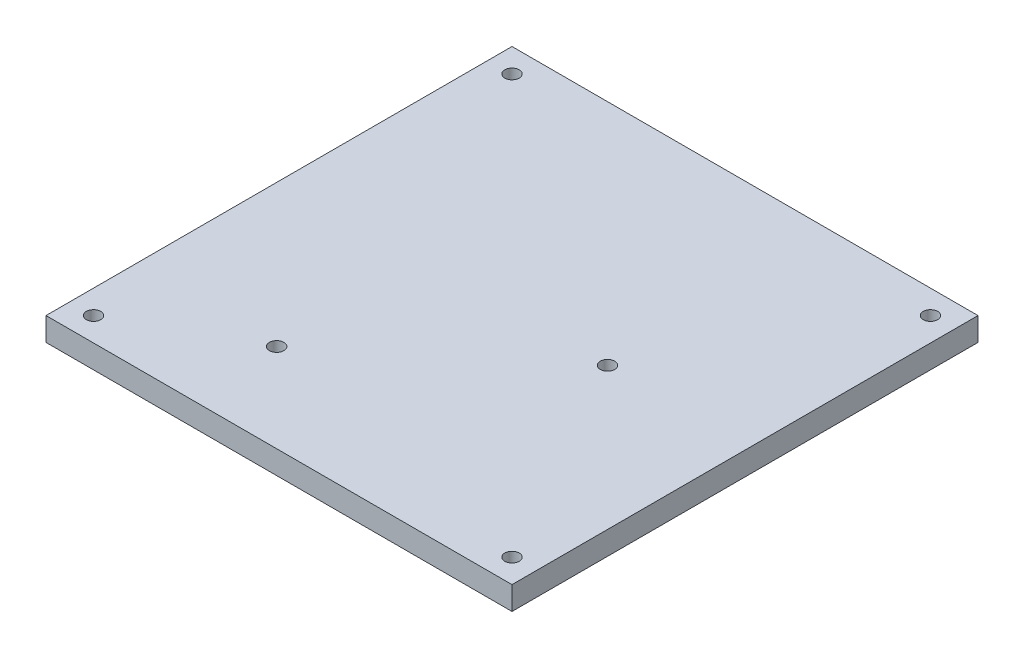
from build123d import *

# Parameters (mm, degrees)
SKETCH1_W           = 100
SKETCH1_H           = 100
SKETCH1_R           = 1.55
BOSS_EXTRUDE1_DEPTH = 5


with BuildPart() as part:
    # Sketch1 → Boss-Extrude1 (new body)
    with BuildSketch(Plane(origin=(0, 0, 0), x_dir=(1, 0, 0), z_dir=(0, 1, 0))):
        Rectangle(SKETCH1_W, SKETCH1_H)
        with Locations((-44.9, 44.9)):
            Circle(SKETCH1_R, mode=Mode.SUBTRACT)
        with Locations((44.9, 44.9)):
            Circle(SKETCH1_R, mode=Mode.SUBTRACT)
        with Locations((44.9, -44.9)):
            Circle(SKETCH1_R, mode=Mode.SUBTRACT)
        with Locations((-44.9, -44.9)):
            Circle(SKETCH1_R, mode=Mode.SUBTRACT)
        with Locations((-19.5, -31)):
            Circle(SKETCH1_R, mode=Mode.SUBTRACT)
        with Locations((19.5, 1)):
            Circle(SKETCH1_R, mode=Mode.SUBTRACT)
    extrude(amount=BOSS_EXTRUDE1_DEPTH)


solid = part.part
